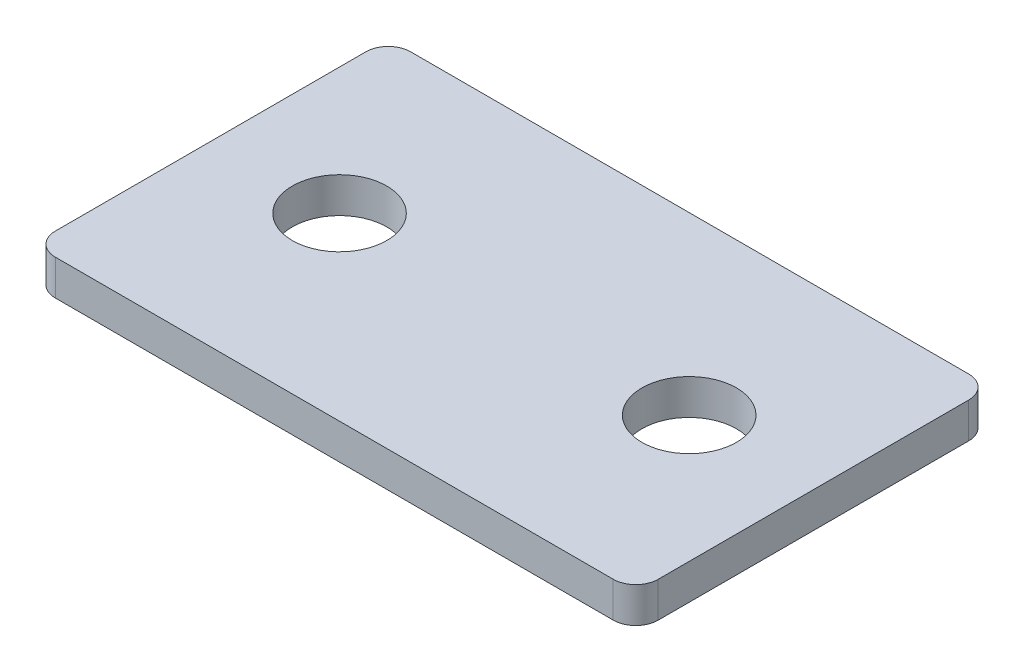
from build123d import *

# Parameters (mm, degrees)
SKETCH1_R           = 2.667
BOSS_EXTRUDE1_DEPTH = 2


with BuildPart() as part:
    # Sketch1 → Boss-Extrude1 (new body)
    with BuildSketch(Plane(origin=(0, 0, 0), x_dir=(1, 0, 0), z_dir=(0, 1, 0))):
        with BuildLine():
            Line((-15.748, 10.033), (15.748, 10.033))
            ThreePointArc((15.748, 10.033), (16.646025612, 9.661025612), (17.018, 8.763))
            Line((17.018, 8.763), (17.018, -8.763))
            ThreePointArc((17.018, -8.763), (16.646025612, -9.661025612), (15.748, -10.033))
            Line((15.748, -10.033), (-15.748, -10.033))
            ThreePointArc((-15.748, -10.033), (-16.646025612, -9.661025612), (-17.018, -8.763))
            Line((-17.018, -8.763), (-17.018, 8.763))
            ThreePointArc((-17.018, 8.763), (-16.646025612, 9.661025612), (-15.748, 10.033))
        make_face()
        with Locations((-9.868, 0.133)):
            Circle(SKETCH1_R, mode=Mode.SUBTRACT)
        with Locations((9.868, 0.133)):
            Circle(SKETCH1_R, mode=Mode.SUBTRACT)
    extrude(amount=BOSS_EXTRUDE1_DEPTH)


solid = part.part
